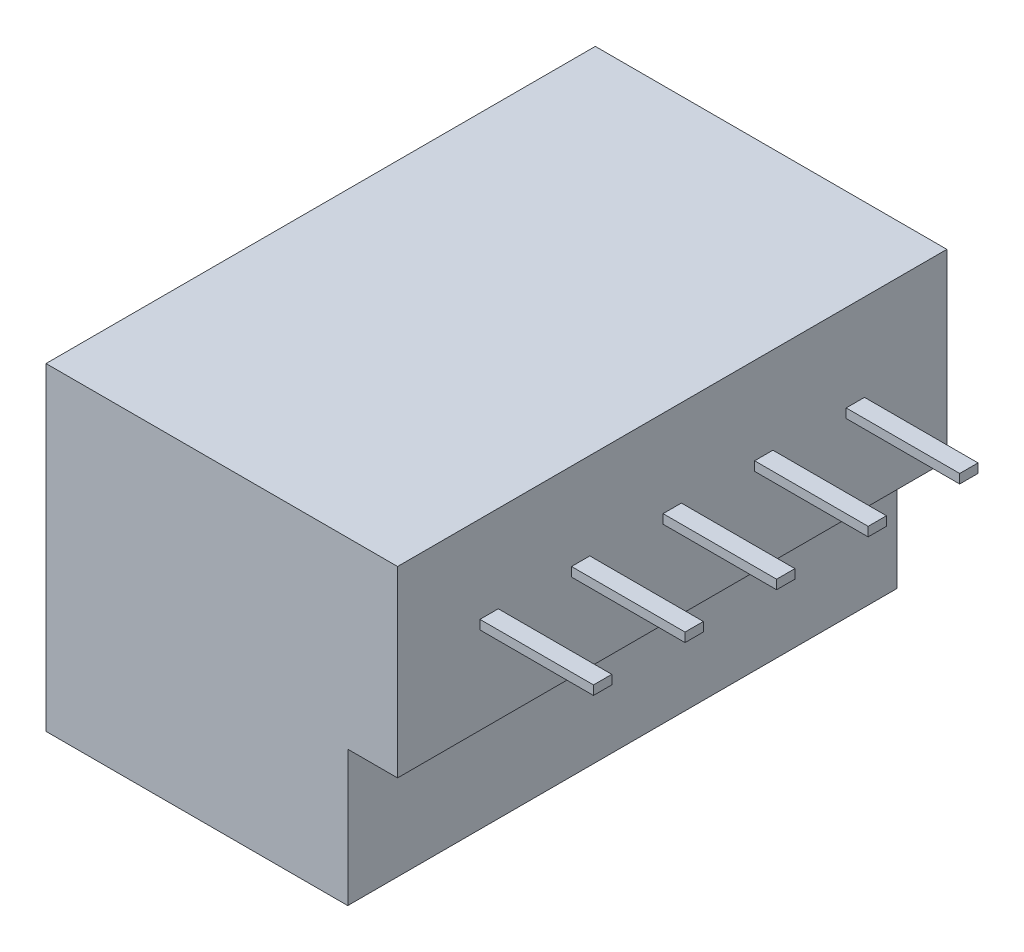
from build123d import *

# Parameters (mm, degrees)
SKETCH1_W           = 8.24
SKETCH1_H           = 15
BOSS_EXTRUDE1_DEPTH = 3.7
BOSS_EXTRUDE2_DEPTH = 5
SKETCH3_W           = 0.5
SKETCH3_H           = 0.25
BOSS_EXTRUDE3_DEPTH = 3.1
SKETCH4_R           = 2.25
SKETCH4_R_2         = 2
CUT_EXTRUDE1_DEPTH  = 0.5


with BuildPart() as part:
    # Sketch1 → Boss-Extrude1 (new body)
    with BuildSketch(Plane(origin=(0, 0, 0), x_dir=(1, 0, 0), z_dir=(0, 1, 0))):
        with Locations((-16.236881088, -0.721940399)):
            Rectangle(SKETCH1_W, SKETCH1_H)
    extrude(amount=BOSS_EXTRUDE1_DEPTH)

    # Sketch2 → Boss-Extrude2 (add)
    with BuildSketch(Plane(origin=(0, 3.7, 0), x_dir=(1, 0, 0), z_dir=(0, 1, 0))):
        Polygon((-20.356881088, -8.221940399), (-12.116881088, -8.221940399), (-10.756881088, -8.221940399), (-10.756881088, 6.778059601), (-12.116881088, 6.778059601), (-20.356881088, 6.778059601), align=None)
    extrude(amount=BOSS_EXTRUDE2_DEPTH)

    # Sketch3 → Boss-Extrude3 (add)
    with BuildSketch(Plane(origin=(-10.756881088, 0, 0), x_dir=(0, 0, -1), z_dir=(1, 0, 0))):
        with Locations((-5.721940399, 6.2)):
            Rectangle(SKETCH3_W, SKETCH3_H)
        with Locations((-3.221940399, 6.2)):
            Rectangle(SKETCH3_W, SKETCH3_H)
        with Locations((-0.721940399, 6.2)):
            Rectangle(SKETCH3_W, SKETCH3_H)
        with Locations((1.778059601, 6.2)):
            Rectangle(SKETCH3_W, SKETCH3_H)
        with Locations((4.278059601, 6.2)):
            Rectangle(SKETCH3_W, SKETCH3_H)
    extrude(amount=BOSS_EXTRUDE3_DEPTH)

    # Sketch4 → Cut-Extrude1 (cut)
    with BuildSketch(Plane(origin=(0, 0, 0), x_dir=(-1, 0, 0), z_dir=(0, -1, 0))):
        with Locations((16.236881088, -4.721940399)):
            Circle(SKETCH4_R)
        with Locations((16.236881088, 3.278059601)):
            Circle(SKETCH4_R_2)
    extrude(amount=-CUT_EXTRUDE1_DEPTH, mode=Mode.SUBTRACT)


solid = part.part
